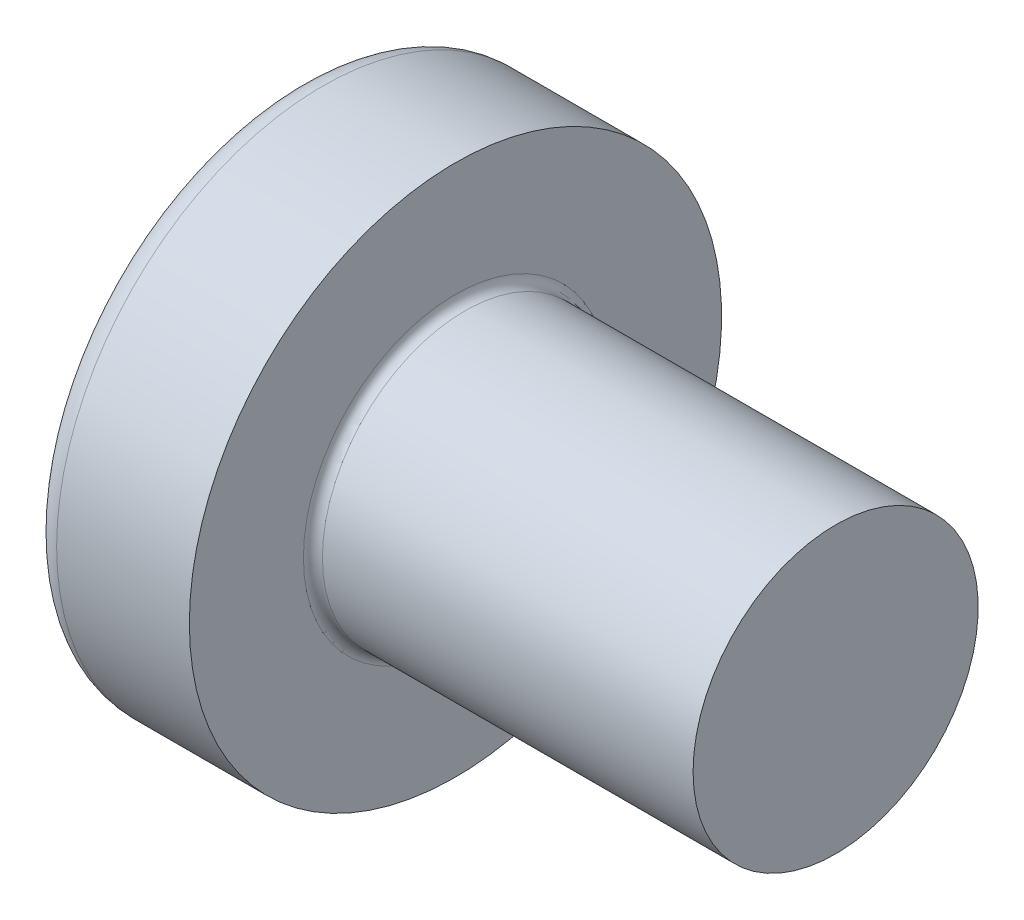
from build123d import *

# Parameters (mm, degrees)
FILLET1_R    = 0.1
SKETCH3_W    = 0.74
SKETCH3_H    = 2.8
SKETCH4_W    = 0.74
SKETCH4_H    = 1.054964432
RECPAT_COUNT = 2
RECPAT_ANGLE = 90


with BuildPart() as part:
    # BodySke → Base-Revolve (revolve)
    with BuildSketch(Plane.XY):
        with BuildLine():
            Line((2.4, 1.5), (2.4, 2.8))
            Line((2.4, 2.8), (1.003501533, 2.8))
            ThreePointArc((1.003501533, 2.8), (0.873295971, 2.76653015), (0.775371599, 2.674418605))
            ThreePointArc((0.775371599, 2.674418605), (0.197753546, 1.392274756), (0, 0))
            Line((0, 0), (6.4, 0))
            Line((6.4, 0), (6.4, 1.5))
            Line((6.4, 1.5), (2.4, 1.5))
        make_face()
    revolve(axis=Axis((-25.4, 0, 0), (1, 0, 0)))

    # Fillet1
    fillet1_edges = [part.edges().sort_by_distance(p)[0] for p in [
        (2.4, -1.5, 0),
    ]]
    fillet(fillet1_edges, radius=FILLET1_R)

    # Sketch3 → Recess section 0
    with BuildSketch(Plane(origin=(0, 0, 0), x_dir=(0, 0, -1), z_dir=(1, 0, 0))):
        Rectangle(SKETCH3_W, SKETCH3_H)
    # Sketch4 → Recess section 1
    with BuildSketch(Plane(origin=(1.75, 0, 0), x_dir=(0, 0, -1), z_dir=(1, 0, 0))):
        Rectangle(SKETCH4_W, SKETCH4_H)
    recess = loft(mode=Mode.SUBTRACT)

    # RecPat: Recess ×2 about axis
    recpat_axis = Axis((0, 0, 0), (1, 0, 0))
    for i in range(1, RECPAT_COUNT):
        add(recess.rotate(recpat_axis, i * RECPAT_ANGLE / (RECPAT_COUNT - 1)), mode=Mode.SUBTRACT)

    # RecCorSke → RecessCore (revolve, cut)
    with BuildSketch(Plane.XY):
        Polygon((0, 0), (0, 0.678371921), (1.75, 0.556), (1.930655351, 0), align=None)
    revolve(axis=Axis((-3.175, 0, 0), (1, 0, 0)), mode=Mode.SUBTRACT)


solid = part.part
